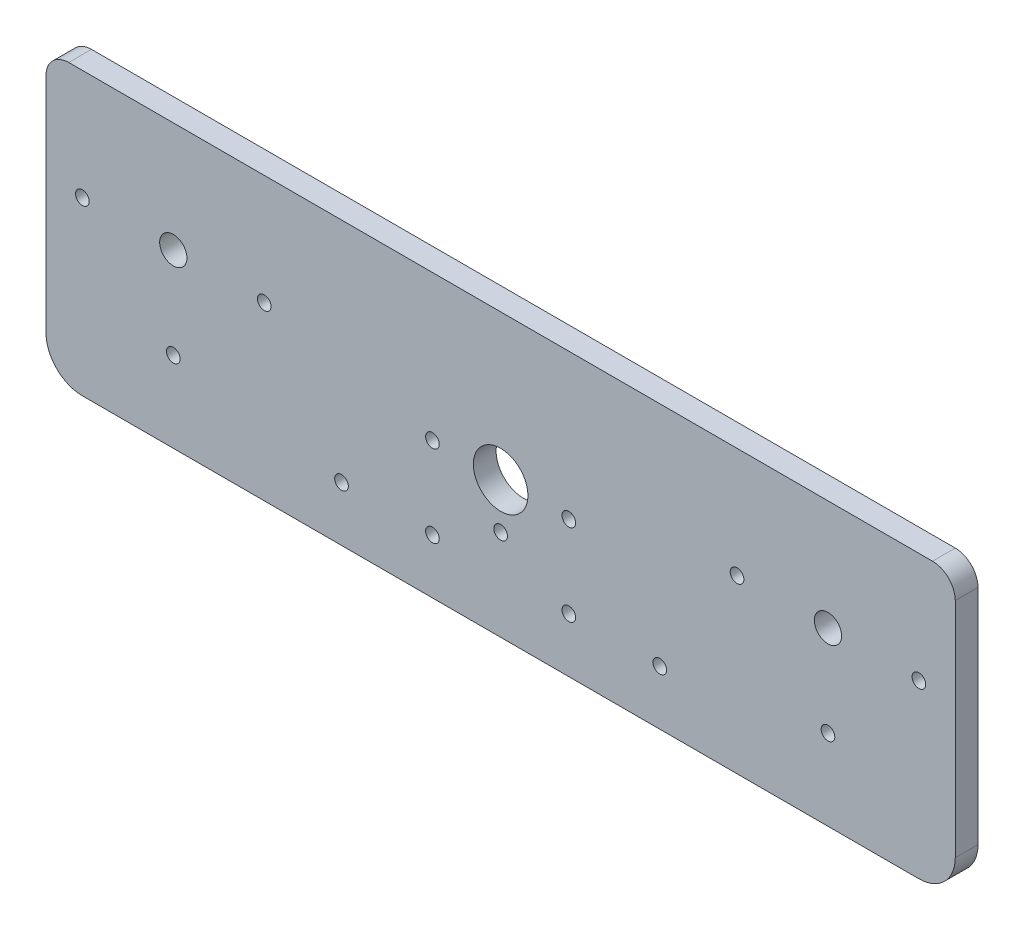
from build123d import *

# Parameters (mm, degrees)
CROQUIS1_R              = 6
CROQUIS1_R_2            = 3
CROQUIS1_R_3            = 1.5
SALIENTE_EXTRUIR1_DEPTH = 5
REDONDEO1_R             = 5


with BuildPart() as part:
    # Croquis1 → Saliente-Extruir1 (new body)
    with BuildSketch(Plane.XY):
        with BuildLine():
            Line((100, 0), (100, -49))
            ThreePointArc((100, -49), (97.656854249, -54.656854249), (92, -57))
            Line((92, -57), (-92, -57))
            ThreePointArc((-92, -57), (-97.656854249, -54.656854249), (-100, -49))
            Line((-100, -49), (-100, 0))
            Line((-100, 0), (-100, 5))
            Line((-100, 5), (100, 5))
            Line((100, 5), (100, 0))
        make_face()
        with Locations((0, -27)):
            Circle(CROQUIS1_R, mode=Mode.SUBTRACT)
        with Locations((72, -19.25)):
            Circle(CROQUIS1_R_2, mode=Mode.SUBTRACT)
        with Locations((-72, -19.25)):
            Circle(CROQUIS1_R_2, mode=Mode.SUBTRACT)
        with Locations((72, -39.25)):
            Circle(CROQUIS1_R_3, mode=Mode.SUBTRACT)
        with Locations((52, -19.25)):
            Circle(CROQUIS1_R_3, mode=Mode.SUBTRACT)
        with Locations((92, -19.25)):
            Circle(CROQUIS1_R_3, mode=Mode.SUBTRACT)
        with Locations((-72, -39.25)):
            Circle(CROQUIS1_R_3, mode=Mode.SUBTRACT)
        with Locations((-92, -19.25)):
            Circle(CROQUIS1_R_3, mode=Mode.SUBTRACT)
        with Locations((-52, -19.25)):
            Circle(CROQUIS1_R_3, mode=Mode.SUBTRACT)
        with Locations((15, -45)):
            Circle(CROQUIS1_R_3, mode=Mode.SUBTRACT)
        with Locations((35, -45)):
            Circle(CROQUIS1_R_3, mode=Mode.SUBTRACT)
        with Locations((-35, -45)):
            Circle(CROQUIS1_R_3, mode=Mode.SUBTRACT)
        with Locations((-15, -45)):
            Circle(CROQUIS1_R_3, mode=Mode.SUBTRACT)
        with Locations((-15, -27)):
            Circle(CROQUIS1_R_3, mode=Mode.SUBTRACT)
        with Locations((15, -27)):
            Circle(CROQUIS1_R_3, mode=Mode.SUBTRACT)
        with Locations((0, -37)):
            Circle(CROQUIS1_R_3, mode=Mode.SUBTRACT)
    extrude(amount=SALIENTE_EXTRUIR1_DEPTH)

    # Redondeo1
    redondeo1_edges = [part.edges().sort_by_distance(p)[0] for p in [
        (-100, 5, 2.5),
        (100, 5, 2.5),
    ]]
    fillet(redondeo1_edges, radius=REDONDEO1_R)


solid = part.part
